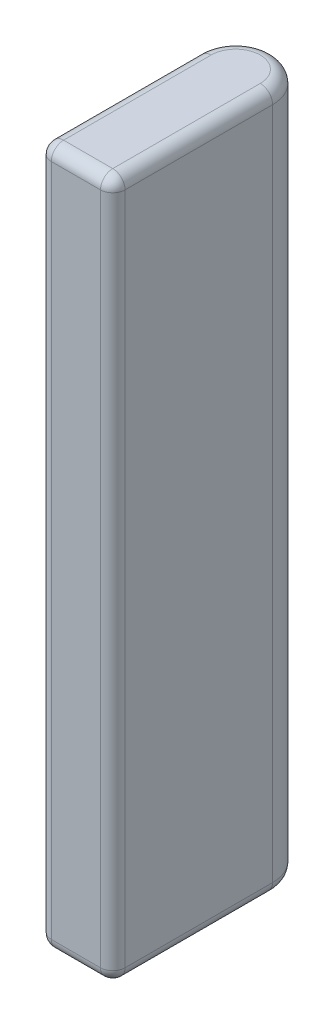
from build123d import *

# Parameters (mm, degrees)
EXTRUDE_1_DEPTH = 28.4
FILLET_1_R      = 0.5


with BuildPart() as part:
    # 草图1 → 凸台-拉伸1 (new body)
    with BuildSketch(Plane(origin=(0, 0, 0), x_dir=(1, 0, 0), z_dir=(0, 1, 0))):
        with BuildLine():
            ThreePointArc((1.5, 3.25), (0, 4.75), (-1.5, 3.25))
            Line((-1.5, 3.25), (1.5, 3.25))
        make_face()
        with BuildLine():
            Line((1.5, 3.25), (-1.5, 3.25))
            ThreePointArc((-1.5, 3.25), (0, 1.75), (1.5, 3.25))
        make_face()
        with BuildLine():
            ThreePointArc((1.5, 3.25), (0, 1.75), (-1.5, 3.25))
            Line((-1.5, 3.25), (-1.5, -3.25))
            Line((-1.5, -3.25), (1.5, -3.25))
            Line((1.5, -3.25), (1.5, 3.25))
        make_face()
    extrude(amount=EXTRUDE_1_DEPTH)

    # 圆角1
    fillet_1_edges = [part.edges().sort_by_distance(p)[0] for p in [
        (-1.5, 28.4, 0),
        (0, 28.4, 3.25),
        (1.5, 28.4, 0),
        (0, 28.4, -4.75),
        (1.5, 0, 0),
        (0, 0, 3.25),
        (-1.5, 0, 0),
        (0, 0, -4.75),
        (1.5, 14.2, 3.25),
        (-1.5, 14.2, 3.25),
    ]]
    fillet(fillet_1_edges, radius=FILLET_1_R)


solid = part.part
